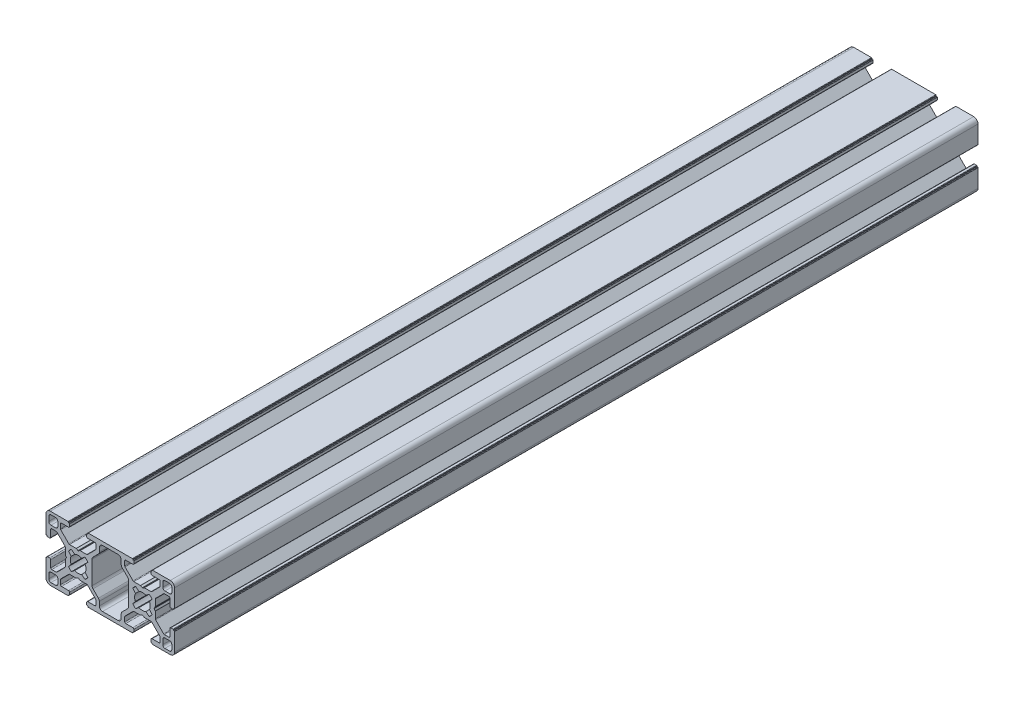
from build123d import *

# Parameters (mm, degrees)
SALIENTE_EXTRUIR1_DEPTH = 375


with BuildPart() as part:
    # Croquis1 → Saliente-Extruir1 (new body)
    with BuildSketch(Plane.XY.offset(1000)):
        with BuildLine():
            Line((-8.899999938, -0.5), (-9.199999128, -0.5))
            Line((-9.199999128, -0.5), (-9.199999128, -0.2))
            ThreePointArc((-9.199999128, -0.2), (-9.258577772, -0.058578644), (-9.399999128, 0))
            Line((-9.399999128, 0), (-17.69999991, 0))
            ThreePointArc((-17.69999991, 0), (-19.114213228, -0.585786336), (-19.699999564, -1.999999654))
            Line((-19.699999564, -1.999999654), (-19.699999564, -10.300000436))
            ThreePointArc((-19.699999564, -10.300000436), (-19.64142092, -10.441421792), (-19.499999564, -10.500000436))
            Line((-19.499999564, -10.500000436), (-19.199999564, -10.500000436))
            Line((-19.199999564, -10.500000436), (-19.199999564, -10.799999626))
            ThreePointArc((-19.199999564, -10.799999626), (-19.141420811, -10.941421247), (-18.99999919, -11))
            Line((-18.99999919, -11), (-17.999998801, -11))
            ThreePointArc((-17.999998801, -11), (-17.646445411, -10.853553391), (-17.499998801, -10.5))
            Line((-17.499998801, -10.5), (-17.499998801, -7.249999673))
            ThreePointArc((-17.499998801, -7.249999673), (-17.353552192, -6.896446282), (-16.999998801, -6.749999673))
            Line((-16.999998801, -6.749999673), (-14.956944055, -6.749999673))
            ThreePointArc((-14.956944055, -6.749999673), (-14.765729738, -6.788007157), (-14.603585721, -6.896251333))
            Line((-14.603585721, -6.896251333), (-10.84664123, -10.649053812))
            ThreePointArc((-10.84664123, -10.649053812), (-10.738112583, -10.811333051), (-10.699999564, -11.002802152))
            Line((-10.699999564, -11.002802152), (-10.699999564, -14.046809855))
            ThreePointArc((-10.699999564, -14.046809855), (-10.693280947, -14.098213231), (-10.673576493, -14.146163012))
            Line((-10.673576493, -14.146163012), (-10.241719845, -14.900646843))
            ThreePointArc((-10.241719845, -14.900646843), (-10.215296774, -15), (-10.241719845, -15.099353157))
            Line((-10.241719845, -15.099353157), (-10.673576493, -15.853836988))
            ThreePointArc((-10.673576493, -15.853836988), (-10.693280947, -15.901786769), (-10.699999564, -15.953190145))
            Line((-10.699999564, -15.953190145), (-10.699999564, -18.997197848))
            ThreePointArc((-10.699999564, -18.997197848), (-10.738112583, -19.188666949), (-10.84664123, -19.350946188))
            Line((-10.84664123, -19.350946188), (-14.603585721, -23.103748667))
            ThreePointArc((-14.603585721, -23.103748667), (-14.765729738, -23.211992843), (-14.956944055, -23.250000327))
            Line((-14.956944055, -23.250000327), (-16.999998801, -23.250000327))
            ThreePointArc((-16.999998801, -23.250000327), (-17.353552192, -23.103553718), (-17.499998801, -22.750000327))
            Line((-17.499998801, -22.750000327), (-17.499998801, -19.5))
            ThreePointArc((-17.499998801, -19.5), (-17.646445411, -19.146446609), (-17.999998801, -19))
            Line((-17.999998801, -19), (-18.99999919, -19))
            ThreePointArc((-18.99999919, -19), (-19.141420811, -19.058578753), (-19.199999564, -19.200000374))
            Line((-19.199999564, -19.200000374), (-19.199999564, -19.499999564))
            Line((-19.199999564, -19.499999564), (-19.499999564, -19.499999564))
            ThreePointArc((-19.499999564, -19.499999564), (-19.64142092, -19.558578208), (-19.699999564, -19.699999564))
            Line((-19.699999564, -19.699999564), (-19.699999564, -28.000000346))
            ThreePointArc((-19.699999564, -28.000000346), (-19.114213228, -29.414213664), (-17.69999991, -30))
            Line((-17.69999991, -30), (-9.399999128, -30))
            ThreePointArc((-9.399999128, -30), (-9.258577772, -29.941421356), (-9.199999128, -29.8))
            Line((-9.199999128, -29.8), (-9.199999128, -29.5))
            Line((-9.199999128, -29.5), (-8.899999938, -29.5))
            ThreePointArc((-8.899999938, -29.5), (-8.758578317, -29.441421247), (-8.699999564, -29.299999626))
            Line((-8.699999564, -29.299999626), (-8.699999564, -28.299999564))
            ThreePointArc((-8.699999564, -28.299999564), (-8.846446174, -27.946446174), (-9.199999564, -27.799999564))
            Line((-9.199999564, -27.799999564), (-12.449999564, -27.799999564))
            ThreePointArc((-12.449999564, -27.799999564), (-12.803552955, -27.653552955), (-12.949999564, -27.299999564))
            Line((-12.949999564, -27.299999564), (-12.949999564, -25.257106345))
            ThreePointArc((-12.949999564, -25.257106345), (-12.91193933, -25.065764629), (-12.803552955, -24.903552955))
            Line((-12.803552955, -24.903552955), (-9.05091204, -21.15091204))
            ThreePointArc((-9.05091204, -21.15091204), (-8.888700365, -21.042525664), (-8.697358649, -21.00446543))
            Line((-8.697358649, -21.00446543), (-5.653588864, -21.00446543))
            ThreePointArc((-5.653588864, -21.00446543), (-5.601825197, -20.997650633), (-5.553589118, -20.977670657))
            Line((-5.553589118, -20.977670657), (-4.799999311, -20.54258685))
            ThreePointArc((-4.799999311, -20.54258685), (-4.699999564, -20.515792077), (-4.599999818, -20.54258685))
            Line((-4.599999818, -20.54258685), (-3.846410011, -20.977670657))
            ThreePointArc((-3.846410011, -20.977670657), (-3.798173932, -20.997650633), (-3.746410264, -21.00446543))
            Line((-3.746410264, -21.00446543), (-0.702640479, -21.00446543))
            ThreePointArc((-0.702640479, -21.00446543), (-0.511298763, -21.042525664), (-0.349087089, -21.15091204))
            Line((-0.349087089, -21.15091204), (3.403553826, -24.903552955))
            ThreePointArc((3.403553826, -24.903552955), (3.511940202, -25.065764629), (3.550000436, -25.257106345))
            Line((3.550000436, -25.257106345), (3.550000436, -27.299999564))
            ThreePointArc((3.550000436, -27.299999564), (3.403553826, -27.653552955), (3.050000436, -27.799999564))
            Line((3.050000436, -27.799999564), (-0.199999564, -27.799999564))
            ThreePointArc((-0.199999564, -27.799999564), (-0.553552955, -27.946446174), (-0.699999564, -28.299999564))
            Line((-0.699999564, -28.299999564), (-0.699999564, -29.299999626))
            ThreePointArc((-0.699999564, -29.299999626), (-0.641420811, -29.441421247), (-0.499999191, -29.5))
            Line((-0.499999191, -29.5), (-0.2, -29.5))
            Line((-0.2, -29.5), (-0.2, -29.799999619))
            ThreePointArc((-0.2, -29.799999619), (-0.141421245, -29.941421245), (3.81e-07, -30))
            Line((3.81e-07, -30), (20.600000491, -30))
            ThreePointArc((20.600000491, -30), (20.741422116, -29.941421245), (20.800000872, -29.799999619))
            Line((20.800000872, -29.799999619), (20.800000872, -29.5))
            Line((20.800000872, -29.5), (21.100000062, -29.5))
            ThreePointArc((21.100000062, -29.5), (21.241421683, -29.441421247), (21.300000436, -29.299999626))
            Line((21.300000436, -29.299999626), (21.300000436, -28.299999564))
            ThreePointArc((21.300000436, -28.299999564), (21.153553826, -27.946446174), (20.800000436, -27.799999564))
            Line((20.800000436, -27.799999564), (17.550000436, -27.799999564))
            ThreePointArc((17.550000436, -27.799999564), (17.196447045, -27.653552955), (17.050000436, -27.299999564))
            Line((17.050000436, -27.299999564), (17.050000436, -25.257106345))
            ThreePointArc((17.050000436, -25.257106345), (17.08806067, -25.065764629), (17.196447045, -24.903552955))
            Line((17.196447045, -24.903552955), (20.94908796, -21.15091204))
            ThreePointArc((20.94908796, -21.15091204), (21.111299635, -21.042525664), (21.302641351, -21.00446543))
            Line((21.302641351, -21.00446543), (24.346411136, -21.00446543))
            ThreePointArc((24.346411136, -21.00446543), (24.398174803, -20.997650633), (24.446410882, -20.977670657))
            Line((24.446410882, -20.977670657), (25.200000689, -20.54258685))
            ThreePointArc((25.200000689, -20.54258685), (25.300000436, -20.515792077), (25.400000182, -20.54258685))
            Line((25.400000182, -20.54258685), (26.153589989, -20.977670657))
            ThreePointArc((26.153589989, -20.977670657), (26.201826068, -20.997650633), (26.253589736, -21.00446543))
            Line((26.253589736, -21.00446543), (29.297359521, -21.00446543))
            ThreePointArc((29.297359521, -21.00446543), (29.488701237, -21.042525664), (29.650912911, -21.15091204))
            Line((29.650912911, -21.15091204), (33.403553826, -24.903552955))
            ThreePointArc((33.403553826, -24.903552955), (33.511940202, -25.065764629), (33.550000436, -25.257106345))
            Line((33.550000436, -25.257106345), (33.550000436, -27.299999564))
            ThreePointArc((33.550000436, -27.299999564), (33.403553826, -27.653552955), (33.050000436, -27.799999564))
            Line((33.050000436, -27.799999564), (29.800000436, -27.799999564))
            ThreePointArc((29.800000436, -27.799999564), (29.446447045, -27.946446174), (29.300000436, -28.299999564))
            Line((29.300000436, -28.299999564), (29.300000436, -29.299999626))
            ThreePointArc((29.300000436, -29.299999626), (29.358579189, -29.441421247), (29.500000809, -29.5))
            Line((29.500000809, -29.5), (29.8, -29.5))
            Line((29.8, -29.5), (29.8, -29.8))
            ThreePointArc((29.8, -29.8), (29.858578644, -29.941421356), (30, -30))
            Line((30, -30), (38.300000782, -30))
            ThreePointArc((38.300000782, -30), (39.7142141, -29.414213664), (40.300000436, -28.000000346))
            Line((40.300000436, -28.000000346), (40.300000436, -19.699999564))
            ThreePointArc((40.300000436, -19.699999564), (40.241421792, -19.558578208), (40.100000436, -19.499999564))
            Line((40.100000436, -19.499999564), (39.800000436, -19.499999564))
            Line((39.800000436, -19.499999564), (39.800000436, -19.200000374))
            ThreePointArc((39.800000436, -19.200000374), (39.741421683, -19.058578753), (39.600000062, -19))
            Line((39.600000062, -19), (38.599999673, -19))
            ThreePointArc((38.599999673, -19), (38.246446282, -19.146446609), (38.099999673, -19.5))
            Line((38.099999673, -19.5), (38.099999673, -22.750000327))
            ThreePointArc((38.099999673, -22.750000327), (37.953553064, -23.103553718), (37.599999673, -23.250000327))
            Line((37.599999673, -23.250000327), (35.556944927, -23.250000327))
            ThreePointArc((35.556944927, -23.250000327), (35.36573061, -23.211992843), (35.203586593, -23.103748667))
            Line((35.203586593, -23.103748667), (31.446642102, -19.350946188))
            ThreePointArc((31.446642102, -19.350946188), (31.338113455, -19.188666949), (31.300000436, -18.997197848))
            Line((31.300000436, -18.997197848), (31.300000436, -15.953190145))
            ThreePointArc((31.300000436, -15.953190145), (31.293281818, -15.901786769), (31.273577365, -15.853836988))
            Line((31.273577365, -15.853836988), (30.841720717, -15.099353157))
            ThreePointArc((30.841720717, -15.099353157), (30.815297646, -15), (30.841720717, -14.900646843))
            Line((30.841720717, -14.900646843), (31.273577365, -14.146163012))
            ThreePointArc((31.273577365, -14.146163012), (31.293281818, -14.098213231), (31.300000436, -14.046809855))
            Line((31.300000436, -14.046809855), (31.300000436, -11.002802152))
            ThreePointArc((31.300000436, -11.002802152), (31.338113455, -10.811333051), (31.446642102, -10.649053812))
            Line((31.446642102, -10.649053812), (35.203586593, -6.896251333))
            ThreePointArc((35.203586593, -6.896251333), (35.36573061, -6.788007157), (35.556944927, -6.749999673))
            Line((35.556944927, -6.749999673), (37.599999673, -6.749999673))
            ThreePointArc((37.599999673, -6.749999673), (37.953553064, -6.896446282), (38.099999673, -7.249999673))
            Line((38.099999673, -7.249999673), (38.099999673, -10.5))
            ThreePointArc((38.099999673, -10.5), (38.246446282, -10.853553391), (38.599999673, -11))
            Line((38.599999673, -11), (39.600000062, -11))
            ThreePointArc((39.600000062, -11), (39.741421683, -10.941421247), (39.800000436, -10.799999626))
            Line((39.800000436, -10.799999626), (39.800000436, -10.500000436))
            Line((39.800000436, -10.500000436), (40.100000436, -10.500000436))
            ThreePointArc((40.100000436, -10.500000436), (40.241421792, -10.441421792), (40.300000436, -10.300000436))
            Line((40.300000436, -10.300000436), (40.300000436, -1.999999654))
            ThreePointArc((40.300000436, -1.999999654), (39.7142141, -0.585786336), (38.300000782, 0))
            Line((38.300000782, 0), (30, 0))
            ThreePointArc((30, 0), (29.858578644, -0.058578644), (29.8, -0.2))
            Line((29.8, -0.2), (29.8, -0.5))
            Line((29.8, -0.5), (29.500000809, -0.5))
            ThreePointArc((29.500000809, -0.5), (29.358579189, -0.558578753), (29.300000436, -0.700000374))
            Line((29.300000436, -0.700000374), (29.300000436, -1.700000436))
            ThreePointArc((29.300000436, -1.700000436), (29.446447045, -2.053553826), (29.800000436, -2.200000436))
            Line((29.800000436, -2.200000436), (33.050000436, -2.200000436))
            ThreePointArc((33.050000436, -2.200000436), (33.403553826, -2.346447045), (33.550000436, -2.700000436))
            Line((33.550000436, -2.700000436), (33.550000436, -4.742893655))
            ThreePointArc((33.550000436, -4.742893655), (33.511940202, -4.934235371), (33.403553826, -5.096447045))
            Line((33.403553826, -5.096447045), (29.650912911, -8.84908796))
            ThreePointArc((29.650912911, -8.84908796), (29.488701237, -8.957474336), (29.297359521, -8.99553457))
            Line((29.297359521, -8.99553457), (26.253589736, -8.99553457))
            ThreePointArc((26.253589736, -8.99553457), (26.201826068, -9.002349367), (26.153589989, -9.022329343))
            Line((26.153589989, -9.022329343), (25.400000182, -9.45741315))
            ThreePointArc((25.400000182, -9.45741315), (25.300000436, -9.484207923), (25.200000689, -9.45741315))
            Line((25.200000689, -9.45741315), (24.446410882, -9.022329343))
            ThreePointArc((24.446410882, -9.022329343), (24.398174803, -9.002349367), (24.346411136, -8.99553457))
            Line((24.346411136, -8.99553457), (21.302641351, -8.99553457))
            ThreePointArc((21.302641351, -8.99553457), (21.111299635, -8.957474336), (20.94908796, -8.84908796))
            Line((20.94908796, -8.84908796), (17.196447045, -5.096447045))
            ThreePointArc((17.196447045, -5.096447045), (17.08806067, -4.934235371), (17.050000436, -4.742893655))
            Line((17.050000436, -4.742893655), (17.050000436, -2.700000436))
            ThreePointArc((17.050000436, -2.700000436), (17.196447045, -2.346447045), (17.550000436, -2.200000436))
            Line((17.550000436, -2.200000436), (20.800000436, -2.200000436))
            ThreePointArc((20.800000436, -2.200000436), (21.153553826, -2.053553826), (21.300000436, -1.700000436))
            Line((21.300000436, -1.700000436), (21.300000436, -0.700000374))
            ThreePointArc((21.300000436, -0.700000374), (21.241421683, -0.558578753), (21.100000062, -0.5))
            Line((21.100000062, -0.5), (20.800000872, -0.5))
            Line((20.800000872, -0.5), (20.800000872, -0.2))
            ThreePointArc((20.800000872, -0.2), (20.741422228, -0.058578644), (20.600000872, 0))
            Line((20.600000872, 0), (0, 0))
            ThreePointArc((0, 0), (-0.141421356, -0.058578644), (-0.2, -0.2))
            Line((-0.2, -0.2), (-0.2, -0.5))
            Line((-0.2, -0.5), (-0.499999191, -0.5))
            ThreePointArc((-0.499999191, -0.5), (-0.641420811, -0.558578753), (-0.699999564, -0.700000374))
            Line((-0.699999564, -0.700000374), (-0.699999564, -1.700000436))
            ThreePointArc((-0.699999564, -1.700000436), (-0.553552955, -2.053553826), (-0.199999564, -2.200000436))
            Line((-0.199999564, -2.200000436), (3.050000436, -2.200000436))
            ThreePointArc((3.050000436, -2.200000436), (3.403553826, -2.346447045), (3.550000436, -2.700000436))
            Line((3.550000436, -2.700000436), (3.550000436, -4.742893655))
            ThreePointArc((3.550000436, -4.742893655), (3.511940202, -4.934235371), (3.403553826, -5.096447045))
            Line((3.403553826, -5.096447045), (-0.349087089, -8.84908796))
            ThreePointArc((-0.349087089, -8.84908796), (-0.511298763, -8.957474336), (-0.702640479, -8.99553457))
            Line((-0.702640479, -8.99553457), (-3.746410264, -8.99553457))
            ThreePointArc((-3.746410264, -8.99553457), (-3.798173932, -9.002349367), (-3.846410011, -9.022329343))
            Line((-3.846410011, -9.022329343), (-4.599999818, -9.45741315))
            ThreePointArc((-4.599999818, -9.45741315), (-4.699999564, -9.484207923), (-4.799999311, -9.45741315))
            Line((-4.799999311, -9.45741315), (-5.553589118, -9.022329343))
            ThreePointArc((-5.553589118, -9.022329343), (-5.601825197, -9.002349367), (-5.653588864, -8.99553457))
            Line((-5.653588864, -8.99553457), (-8.697358649, -8.99553457))
            ThreePointArc((-8.697358649, -8.99553457), (-8.888700365, -8.957474336), (-9.05091204, -8.84908796))
            Line((-9.05091204, -8.84908796), (-12.803552955, -5.096447045))
            ThreePointArc((-12.803552955, -5.096447045), (-12.91193933, -4.934235371), (-12.949999564, -4.742893655))
            Line((-12.949999564, -4.742893655), (-12.949999564, -2.700000436))
            ThreePointArc((-12.949999564, -2.700000436), (-12.803552955, -2.346447045), (-12.449999564, -2.200000436))
            Line((-12.449999564, -2.200000436), (-9.199999564, -2.200000436))
            ThreePointArc((-9.199999564, -2.200000436), (-8.846446174, -2.053553826), (-8.699999564, -1.700000436))
            Line((-8.699999564, -1.700000436), (-8.699999564, -0.700000374))
            ThreePointArc((-8.699999564, -0.700000374), (-8.758578317, -0.558578753), (-8.899999938, -0.5))
        make_face()
        with BuildLine():
            Line((-18.399999963, -4.499999682), (-18.399999963, -2.2999989))
            ThreePointArc((-18.399999963, -2.2999989), (-18.107106747, -1.592892126), (-17.399999972, -1.29999891))
            Line((-17.399999972, -1.29999891), (-15.19999919, -1.29999891))
            ThreePointArc((-15.19999919, -1.29999891), (-14.492892416, -1.592892126), (-14.1999992, -2.2999989))
            Line((-14.1999992, -2.2999989), (-14.1999992, -4.499999682))
            ThreePointArc((-14.1999992, -4.499999682), (-14.492892416, -5.207106457), (-15.19999919, -5.499999673))
            Line((-15.19999919, -5.499999673), (-17.399999972, -5.499999673))
            ThreePointArc((-17.399999972, -5.499999673), (-18.107106747, -5.207106457), (-18.399999963, -4.499999682))
        make_face(mode=Mode.SUBTRACT)
        with BuildLine():
            Line((-18.399999963, -27.7000011), (-18.399999963, -25.500000318))
            ThreePointArc((-18.399999963, -25.500000318), (-18.107106747, -24.792893543), (-17.399999972, -24.500000327))
            Line((-17.399999972, -24.500000327), (-15.19999919, -24.500000327))
            ThreePointArc((-15.19999919, -24.500000327), (-14.492892416, -24.792893543), (-14.1999992, -25.500000317))
            Line((-14.1999992, -25.500000317), (-14.1999992, -27.7000011))
            ThreePointArc((-14.1999992, -27.7000011), (-14.492892416, -28.407107874), (-15.19999919, -28.70000109))
            Line((-15.19999919, -28.70000109), (-17.399999972, -28.70000109))
            ThreePointArc((-17.399999972, -28.70000109), (-18.107106747, -28.407107874), (-18.399999963, -27.7000011))
        make_face(mode=Mode.SUBTRACT)
        with BuildLine():
            Line((35.800000062, -1.29999891), (38.000000844, -1.29999891))
            ThreePointArc((38.000000844, -1.29999891), (38.707107618, -1.592892126), (39.000000834, -2.2999989))
            Line((39.000000834, -2.2999989), (39.000000834, -4.499999682))
            ThreePointArc((39.000000834, -4.499999682), (38.707107618, -5.207106457), (38.000000844, -5.499999673))
            Line((38.000000844, -5.499999673), (35.800000062, -5.499999673))
            ThreePointArc((35.800000062, -5.499999673), (35.092893287, -5.207106457), (34.800000071, -4.499999682))
            Line((34.800000071, -4.499999682), (34.800000071, -2.2999989))
            ThreePointArc((34.800000071, -2.2999989), (35.092893287, -1.592892126), (35.800000062, -1.29999891))
        make_face(mode=Mode.SUBTRACT)
        with BuildLine():
            Line((35.800000062, -24.500000327), (38.000000844, -24.500000327))
            ThreePointArc((38.000000844, -24.500000327), (38.707107618, -24.792893543), (39.000000834, -25.500000318))
            Line((39.000000834, -25.500000318), (39.000000834, -27.7000011))
            ThreePointArc((39.000000834, -27.7000011), (38.707107618, -28.407107874), (38.000000844, -28.70000109))
            Line((38.000000844, -28.70000109), (35.800000062, -28.70000109))
            ThreePointArc((35.800000062, -28.70000109), (35.092893287, -28.407107874), (34.800000071, -27.7000011))
            Line((34.800000071, -27.7000011), (34.800000071, -25.500000318))
            ThreePointArc((34.800000071, -25.500000318), (35.092893287, -24.792893543), (35.800000062, -24.500000327))
        make_face(mode=Mode.SUBTRACT)
        with BuildLine():
            Line((-0.181598661, -11.864070588), (-1.419437797, -13.399870476))
            ThreePointArc((-1.419437797, -13.399870476), (-1.049999564, -15), (-1.419437797, -16.600129524))
            Line((-1.419437797, -16.600129524), (-0.181598661, -18.135929412))
            ThreePointArc((-0.181598661, -18.135929412), (-0.802844004, -18.881002259), (-1.545330091, -19.505336892))
            Line((-1.545330091, -19.505336892), (-3.099869968, -18.280561731))
            ThreePointArc((-3.099869968, -18.280561731), (-4.699999564, -18.65), (-6.300129161, -18.280561731))
            Line((-6.300129161, -18.280561731), (-7.854669037, -19.505336892))
            ThreePointArc((-7.854669037, -19.505336892), (-8.597155125, -18.881002259), (-9.218400467, -18.135929412))
            Line((-9.218400467, -18.135929412), (-7.980561331, -16.600129524))
            ThreePointArc((-7.980561331, -16.600129524), (-8.349999564, -15), (-7.980561331, -13.399870476))
            Line((-7.980561331, -13.399870476), (-9.218400467, -11.864070588))
            ThreePointArc((-9.218400467, -11.864070588), (-8.597155125, -11.118997741), (-7.854669037, -10.494663108))
            Line((-7.854669037, -10.494663108), (-6.300129161, -11.719438268))
            ThreePointArc((-6.300129161, -11.719438268), (-4.699999564, -11.35), (-3.099869968, -11.719438268))
            Line((-3.099869968, -11.719438268), (-1.545330091, -10.494663108))
            ThreePointArc((-1.545330091, -10.494663108), (-0.802844004, -11.118997741), (-0.181598661, -11.864070588))
        make_face(mode=Mode.SUBTRACT)
        with BuildLine():
            Line((20.781599533, -18.135929412), (22.019438669, -16.600129524))
            ThreePointArc((22.019438669, -16.600129524), (21.650000436, -15), (22.019438669, -13.399870476))
            Line((22.019438669, -13.399870476), (20.781599533, -11.864070588))
            ThreePointArc((20.781599533, -11.864070588), (21.402844875, -11.118997741), (22.145330963, -10.494663108))
            Line((22.145330963, -10.494663108), (23.699870839, -11.719438268))
            ThreePointArc((23.699870839, -11.719438268), (25.300000436, -11.35), (26.900130032, -11.719438268))
            Line((26.900130032, -11.719438268), (28.454669909, -10.494663108))
            ThreePointArc((28.454669909, -10.494663108), (29.197155996, -11.118997741), (29.818401339, -11.864070588))
            Line((29.818401339, -11.864070588), (28.580562203, -13.399870476))
            ThreePointArc((28.580562203, -13.399870476), (28.950000436, -15), (28.580562203, -16.600129524))
            Line((28.580562203, -16.600129524), (29.818401339, -18.135929412))
            ThreePointArc((29.818401339, -18.135929412), (29.197155996, -18.881002259), (28.454669909, -19.505336892))
            Line((28.454669909, -19.505336892), (26.900130032, -18.280561731))
            ThreePointArc((26.900130032, -18.280561731), (25.300000436, -18.65), (23.699870839, -18.280561731))
            Line((23.699870839, -18.280561731), (22.145330963, -19.505336892))
            ThreePointArc((22.145330963, -19.505336892), (21.402844875, -18.881002259), (20.781599533, -18.135929412))
        make_face(mode=Mode.SUBTRACT)
        with BuildLine():
            Line((18.795534229, -9.650306182), (18.795534229, -20.349693818))
            ThreePointArc((18.795534229, -20.349693818), (18.681353508, -20.923719014), (18.356194328, -21.410354062))
            Line((18.356194328, -21.410354062), (15.839340301, -23.927207746))
            ThreePointArc((15.839340301, -23.927207746), (15.514181147, -24.413842755), (15.400000436, -24.987867904))
            Line((15.400000436, -24.987867904), (15.400000436, -26.849999904))
            ThreePointArc((15.400000436, -26.849999904), (14.960660608, -27.910660076), (13.900000436, -28.349999904))
            Line((13.900000436, -28.349999904), (6.700000436, -28.349999904))
            ThreePointArc((6.700000436, -28.349999904), (5.639340264, -27.910660076), (5.200000436, -26.849999904))
            Line((5.200000436, -26.849999904), (5.200000436, -24.987867904))
            ThreePointArc((5.200000436, -24.987867904), (5.085819724, -24.413842755), (4.760660571, -23.927207746))
            Line((4.760660571, -23.927207746), (2.243806544, -21.410354062))
            ThreePointArc((2.243806544, -21.410354062), (1.918647364, -20.923719014), (1.804466643, -20.349693818))
            Line((1.804466643, -20.349693818), (1.804466643, -9.650306182))
            ThreePointArc((1.804466643, -9.650306182), (1.918647364, -9.076280986), (2.243806544, -8.589645938))
            Line((2.243806544, -8.589645938), (4.760660571, -6.072792254))
            ThreePointArc((4.760660571, -6.072792254), (5.085819724, -5.586157245), (5.200000436, -5.012132096))
            Line((5.200000436, -5.012132096), (5.200000436, -3.150000096))
            ThreePointArc((5.200000436, -3.150000096), (5.639340264, -2.089339924), (6.700000436, -1.650000096))
            Line((6.700000436, -1.650000096), (13.900000436, -1.650000096))
            ThreePointArc((13.900000436, -1.650000096), (14.960660608, -2.089339924), (15.400000436, -3.150000096))
            Line((15.400000436, -3.150000096), (15.400000436, -5.012132096))
            ThreePointArc((15.400000436, -5.012132096), (15.514181147, -5.586157245), (15.839340301, -6.072792254))
            Line((15.839340301, -6.072792254), (18.356194328, -8.589645938))
            ThreePointArc((18.356194328, -8.589645938), (18.681353508, -9.076280986), (18.795534229, -9.650306182))
        make_face(mode=Mode.SUBTRACT)
    extrude(amount=-SALIENTE_EXTRUIR1_DEPTH)


solid = part.part
